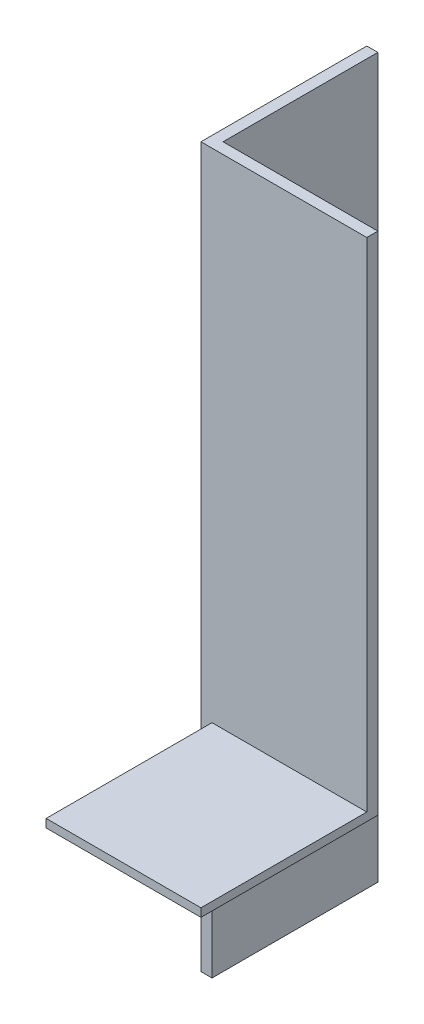
from build123d import *

# Parameters (mm, degrees)
EXTRUDE_1_DEPTH     = 65
CUT_EXTRUDE_START   = -20
SKETCH_6_W          = 14
SKETCH_6_H          = 1
CUT_EXTRUDE_2_DEPTH = 20
SKETCH_7_W          = 14
SKETCH_7_H          = 0.75
EXTRUDE_2_DEPTH     = 16


with BuildPart() as part:
    # Эскиз1 → Бобышка-Вытянуть1 (new body)
    with BuildSketch(Plane(origin=(0, 0, 0), x_dir=(1, 0, 0), z_dir=(0, 1, 0))):
        Polygon((0, 0), (0, 15), (1, 15), (1, 1), (15, 1), (15, 0), align=None)
    extrude(amount=EXTRUDE_1_DEPTH)

    # Эскиз6 → Вырез-Вытянуть2 (cut)
    with BuildSketch(Plane.XZ.offset(CUT_EXTRUDE_START)):
        with Locations((8, -0.5)):
            Rectangle(SKETCH_6_W, SKETCH_6_H)
    extrude(amount=CUT_EXTRUDE_2_DEPTH, mode=Mode.SUBTRACT)

    # Эскиз7 → Бобышка-Вытянуть2 (add)
    with BuildSketch(Plane(origin=(0, 0, -1), x_dir=(-1, 0, 0), z_dir=(0, 0, -1))):
        with Locations((-8, 19.625)):
            Rectangle(SKETCH_7_W, SKETCH_7_H)
    extrude(amount=-EXTRUDE_2_DEPTH)


solid = part.part
